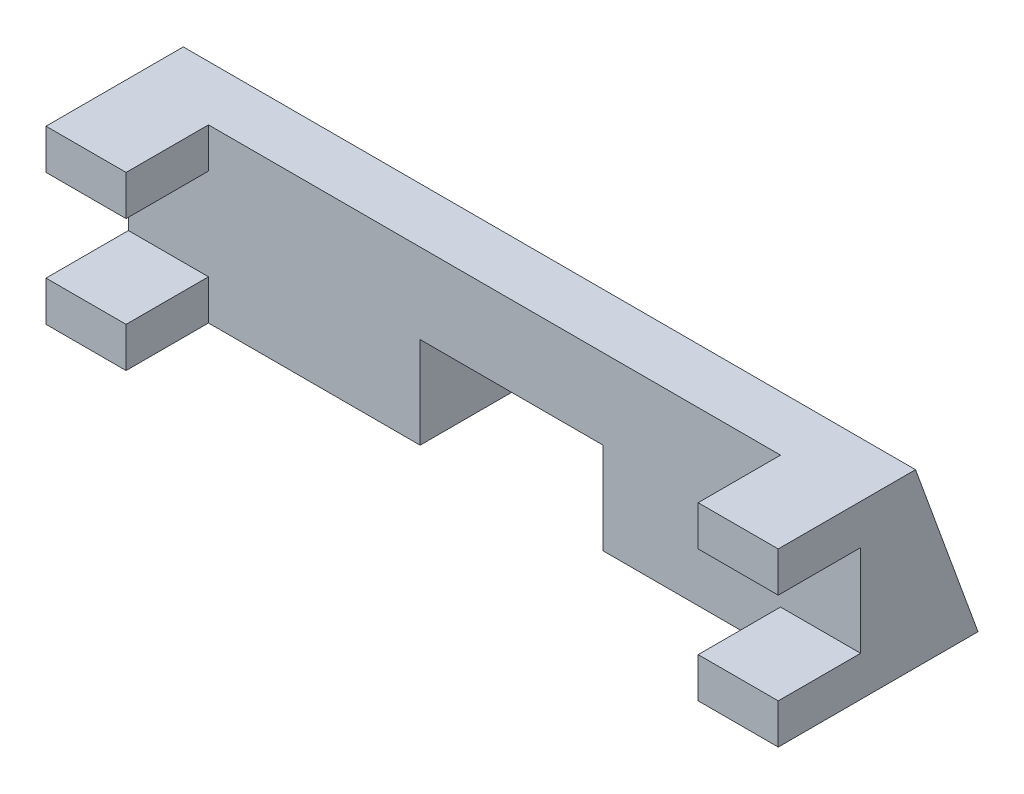
from build123d import *

# Parameters (mm, degrees)
BOSS_EXTRUDE1_DEPTH     = 64
SKETCH2_W               = 50
SKETCH2_H               = 7.2
CUT_EXTRUDE1_DEPTH      = 12.5
CUT_EXTRUDE1_DEPTH_BACK = 4.5
SKETCH3_W               = 16
SKETCH3_H               = 8
CUT_EXTRUDE2_DEPTH      = 64


with BuildPart() as part:
    # Sketch1 → Boss-Extrude1 (new body)
    with BuildSketch(Plane(origin=(0, 0, 0), x_dir=(0, 0, -1), z_dir=(1, 0, 0))):
        Polygon((0.359176952, -3.317134482), (0.359176952, 0.182865518), (12.359176952, 0.182865518), (17.818730466, -14.817134482), (12.359176952, -14.817134482), (0.359176952, -14.817134482), (0.359176952, -11.317134482), (7.559176952, -11.317134482), (7.559176952, -3.317134482), align=None)
    extrude(amount=BOSS_EXTRUDE1_DEPTH)

    # Sketch2 → Cut-Extrude1 (cut, two sides)
    with BuildSketch(Plane(origin=(0, -11.317134482, 0), x_dir=(1, 0, 0), z_dir=(0, 1, 0))) as cut_extrude1_sk:
        with Locations((32, 3.959176952)):
            Rectangle(SKETCH2_W, SKETCH2_H)
    extrude(amount=CUT_EXTRUDE1_DEPTH, mode=Mode.SUBTRACT)
    extrude(cut_extrude1_sk.sketch, amount=-CUT_EXTRUDE1_DEPTH_BACK, mode=Mode.SUBTRACT)

    # Sketch3 → Cut-Extrude2 (cut)
    with BuildSketch(Plane.XY.offset(-7.559176952)):
        with Locations((33.5, -10.817134482)):
            Rectangle(SKETCH3_W, SKETCH3_H)
    extrude(amount=-CUT_EXTRUDE2_DEPTH, mode=Mode.SUBTRACT)


solid = part.part
